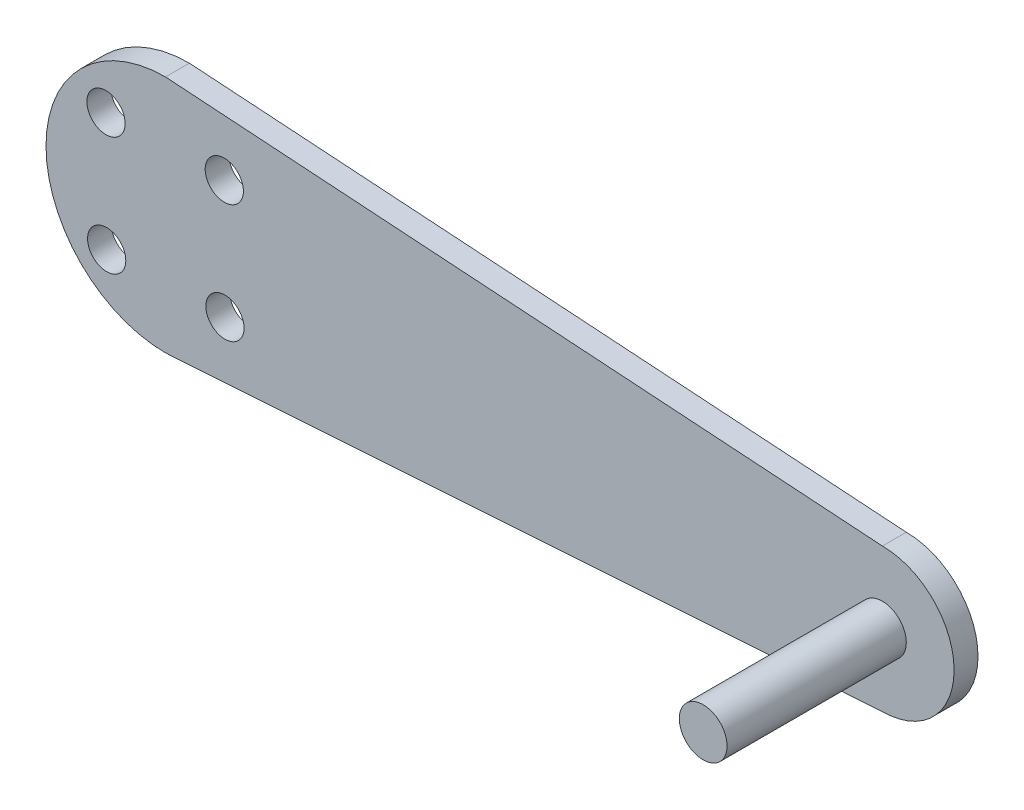
from build123d import *

# Parameters (mm, degrees)
BOSS_EXTRUDE1_DEPTH = 2
SKETCH2_R           = 1.6
CUT_EXTRUDE1_DEPTH  = 10
SKETCH3_R           = 2
BOSS_EXTRUDE2_DEPTH = 15


with BuildPart() as part:
    # Sketch1 → Boss-Extrude1 (new body)
    with BuildSketch(Plane.XY):
        with BuildLine():
            ThreePointArc((0, 10), (-10, 0), (0, -10))
            Line((0, -10), (60, -6))
            ThreePointArc((60, -6), (66, 0), (60, 6))
            Line((60, 6), (0, 10))
        make_face()
    extrude(amount=BOSS_EXTRUDE1_DEPTH)

    # Sketch2 → Cut-Extrude1 (cut)
    with BuildSketch(Plane.XY.offset(2)):
        with Locations((-4.977412632, 4.921926807)):
            Circle(SKETCH2_R)
        with Locations((4.921926807, 4.977412632)):
            Circle(SKETCH2_R)
        with Locations((4.977412632, -4.921926807)):
            Circle(SKETCH2_R)
        with Locations((-4.921926807, -4.977412632)):
            Circle(SKETCH2_R)
    extrude(amount=-CUT_EXTRUDE1_DEPTH, mode=Mode.SUBTRACT)

    # Sketch3 → Boss-Extrude2 (add)
    with BuildSketch(Plane.XY.offset(2)):
        with Locations((60, 0)):
            Circle(SKETCH3_R)
    extrude(amount=BOSS_EXTRUDE2_DEPTH)


solid = part.part
